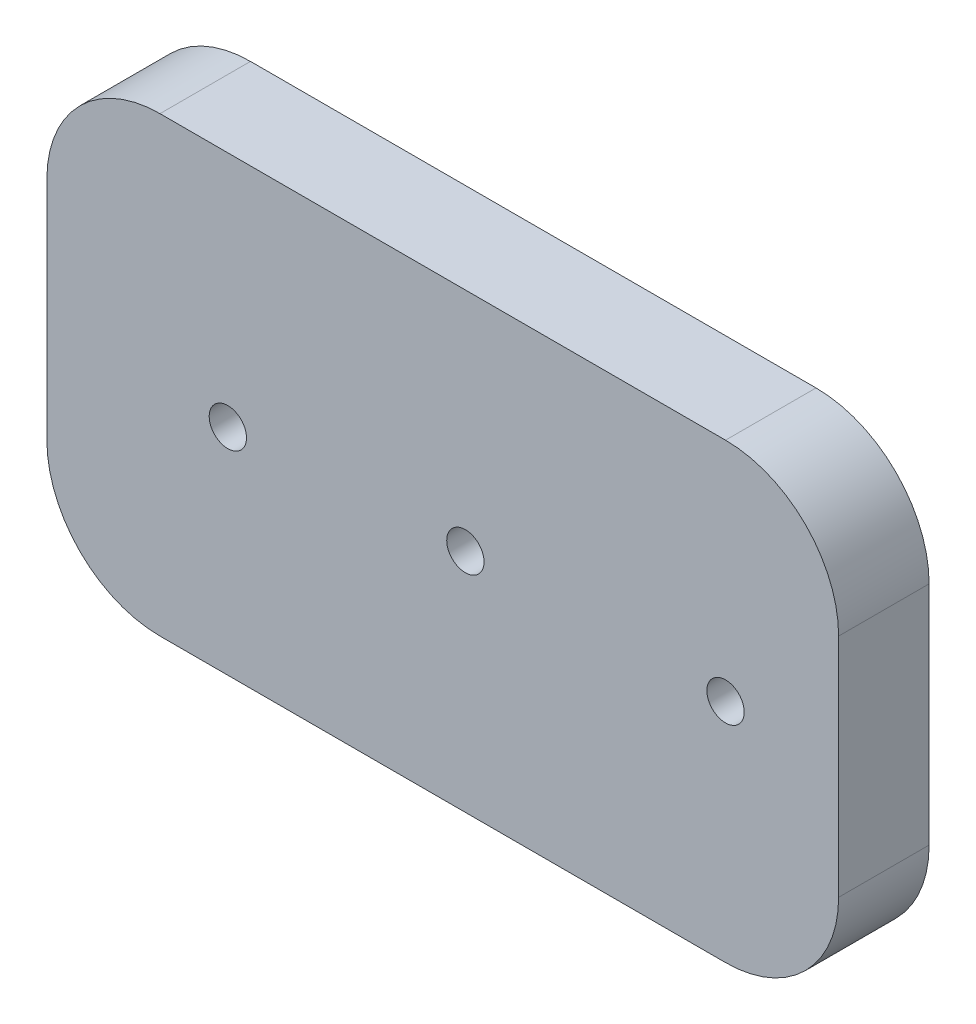
from build123d import *

# Parameters (mm, degrees)
SKETCH1_W           = 70
SKETCH1_H           = 40
BOSS_EXTRUDE1_DEPTH = 10
SKETCH2_R           = 1.65
CUT_EXTRUDE1_DEPTH  = 11
FILLET1_R           = 10
SHELL2_T            = -1
SKETCH3_R           = 2.65
SKETCH3_R_2         = 1.65
BOSS_EXTRUDE2_DEPTH = 4
CUT_EXTRUDE2_DEPTH  = 2


with BuildPart() as part:
    # Sketch1 → Boss-Extrude1 (new body)
    with BuildSketch(Plane.XY):
        Rectangle(SKETCH1_W, SKETCH1_H)
    extrude(amount=BOSS_EXTRUDE1_DEPTH)

    # Sketch2 → Cut-Extrude1 (cut, through all)
    with BuildSketch(Plane(origin=(0, 0, 0), x_dir=(-1, 0, 0), z_dir=(0, 0, -1))):
        with Locations((-25, 0)):
            Circle(SKETCH2_R)
        with Locations((-2, 0)):
            Circle(SKETCH2_R)
        with Locations((19, -1)):
            Circle(SKETCH2_R)
    extrude(amount=-CUT_EXTRUDE1_DEPTH, mode=Mode.SUBTRACT)

    # Fillet1
    fillet1_edges = [part.edges().sort_by_distance(p)[0] for p in [
        (35, -20, 5),
        (-35, -20, 5),
        (-35, 20, 5),
        (35, 20, 5),
    ]]
    fillet(fillet1_edges, radius=FILLET1_R)

    # Shell2
    shell2_openings = [part.faces().sort_by_distance(p)[0] for p in [
        (23.35, 0, 0),
    ]]
    offset(amount=SHELL2_T, openings=shell2_openings, kind=Kind.INTERSECTION)

    # Sketch3 → Boss-Extrude2 (add)
    with BuildSketch(Plane(origin=(0, 0, 0), x_dir=(-1, 0, 0), z_dir=(0, 0, -1))):
        with Locations((-2, 0)):
            Circle(SKETCH3_R)
        with Locations((-2, 0)):
            Circle(SKETCH3_R_2, mode=Mode.SUBTRACT)
        with Locations((-25, 0)):
            Circle(SKETCH3_R)
        with Locations((-25, 0)):
            Circle(SKETCH3_R_2, mode=Mode.SUBTRACT)
    extrude(amount=BOSS_EXTRUDE2_DEPTH)

    # Sketch4 → Cut-Extrude2 (cut)
    with BuildSketch(Plane(origin=(0, 0, 0), x_dir=(-1, 0, 0), z_dir=(0, 0, -1))):
        with BuildLine():
            Line((35, -10), (35, 10))
            ThreePointArc((35, 10), (32.071067812, 17.071067812), (25, 20))
            Line((25, 20), (-25, 20))
            ThreePointArc((-25, 20), (-32.071067812, 17.071067812), (-35, 10))
            Line((-35, 10), (-35, -10))
            ThreePointArc((-35, -10), (-32.071067812, -17.071067812), (-25, -20))
            Line((-25, -20), (25, -20))
            ThreePointArc((25, -20), (32.071067812, -17.071067812), (35, -10))
        make_face()
        with BuildLine():
            Line((33, -10), (33, 10))
            ThreePointArc((33, 10), (30.656854249, 15.656854249), (25, 18))
            Line((25, 18), (-25, 18))
            ThreePointArc((-25, 18), (-30.656854249, 15.656854249), (-33, 10))
            Line((-33, 10), (-33, -10))
            ThreePointArc((-33, -10), (-30.656854249, -15.656854249), (-25, -18))
            Line((-25, -18), (25, -18))
            ThreePointArc((25, -18), (30.656854249, -15.656854249), (33, -10))
        make_face(mode=Mode.SUBTRACT)
    extrude(amount=-CUT_EXTRUDE2_DEPTH, mode=Mode.SUBTRACT)


solid = part.part
